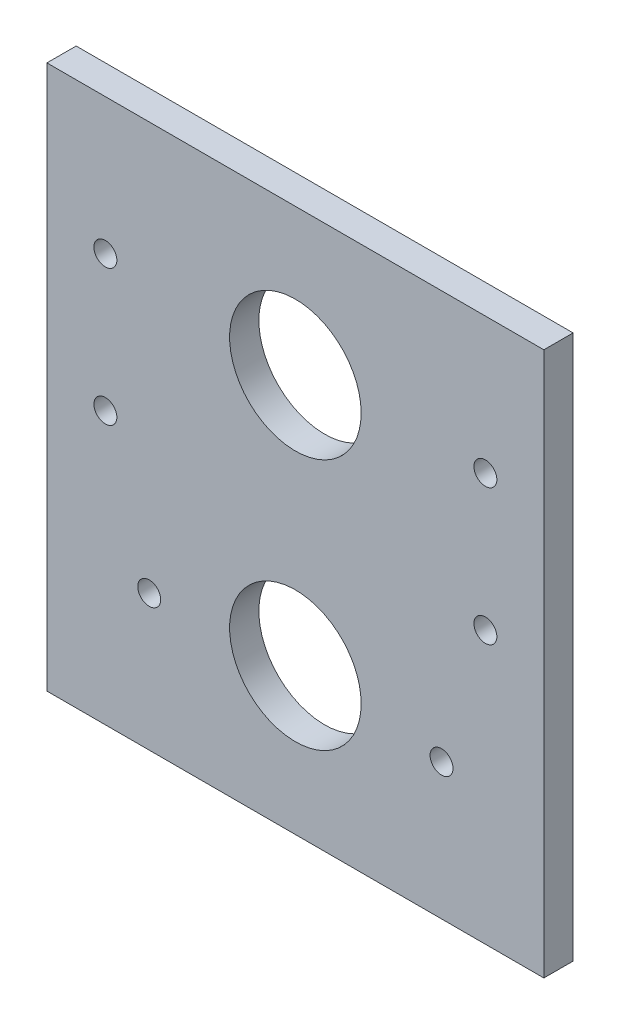
from build123d import *

# Parameters (mm, degrees)
SKETCH1_W           = 107.95
SKETCH1_H           = 118.1862
SKETCH1_R           = 14.2875
SKETCH1_R_2         = 2.4892
BOSS_EXTRUDE1_DEPTH = 6.35


with BuildPart() as part:
    # Sketch1 → Boss-Extrude1 (new body)
    with BuildSketch(Plane.XY):
        with Locations((53.975, 59.0931)):
            Rectangle(SKETCH1_W, SKETCH1_H)
        with Locations((53.975, 86.4362)):
            Circle(SKETCH1_R, mode=Mode.SUBTRACT)
        with Locations((53.975, 31.75)):
            Circle(SKETCH1_R, mode=Mode.SUBTRACT)
        with Locations((95.25, 59.0931)):
            Circle(SKETCH1_R_2, mode=Mode.SUBTRACT)
        with Locations((95.25, 88.63965)):
            Circle(SKETCH1_R_2, mode=Mode.SUBTRACT)
        with Locations((12.7, 88.63965)):
            Circle(SKETCH1_R_2, mode=Mode.SUBTRACT)
        with Locations((12.7, 59.0931)):
            Circle(SKETCH1_R_2, mode=Mode.SUBTRACT)
        with Locations((22.225, 29.54655)):
            Circle(SKETCH1_R_2, mode=Mode.SUBTRACT)
        with Locations((85.725, 29.54655)):
            Circle(SKETCH1_R_2, mode=Mode.SUBTRACT)
    extrude(amount=BOSS_EXTRUDE1_DEPTH)


solid = part.part
